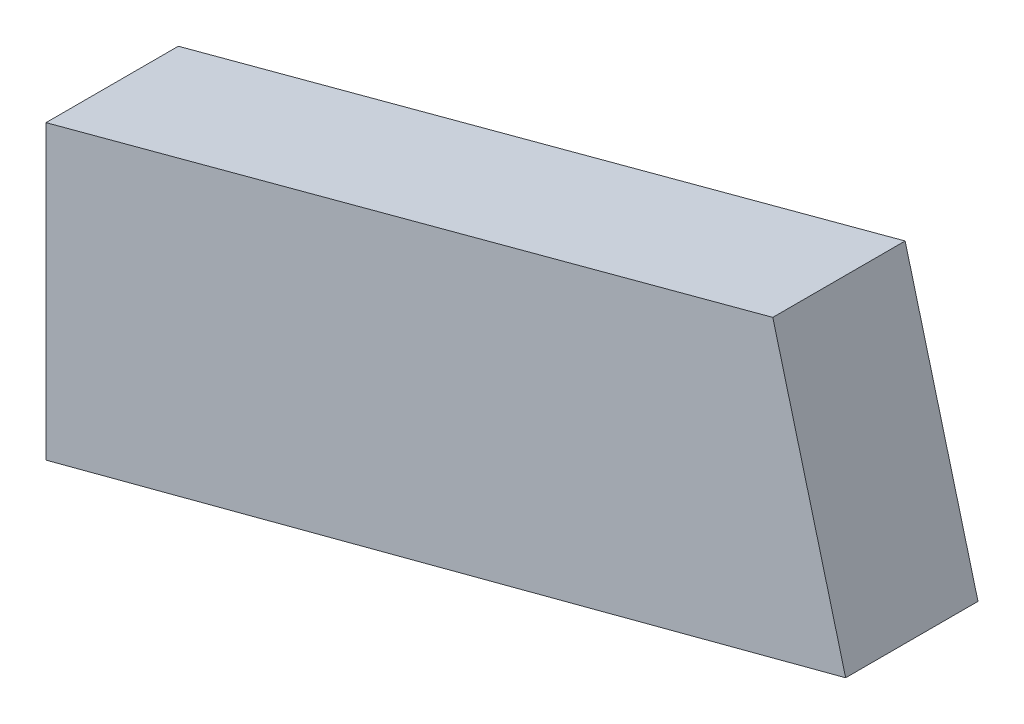
from build123d import *

# Parameters (mm, degrees)
BOSS_EXTRUDE1_DEPTH = 12


with BuildPart() as part:
    # Sketch1 → Boss-Extrude1 (new body)
    with BuildSketch(Plane.XY):
        Polygon((0, 0), (72.510740568, 19.162267669), (65.904040817, 44.162267669), (0, 26.503333154), align=None)
    extrude(amount=BOSS_EXTRUDE1_DEPTH)


solid = part.part
